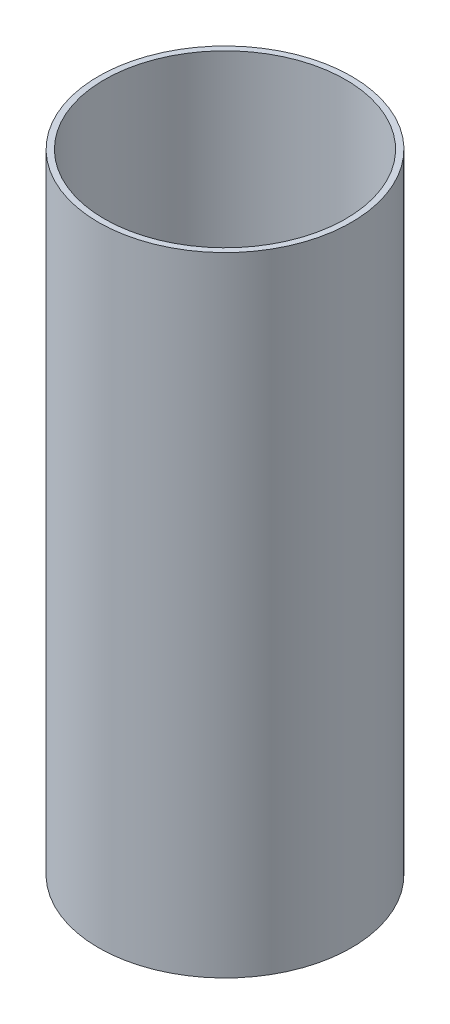
from build123d import *

# Parameters (mm, degrees)
SKETCH1_R           = 59.94
SKETCH1_R_2         = 57.15
BOSS_EXTRUDE1_DEPTH = 297.6


with BuildPart() as part:
    # Sketch1 → Boss-Extrude1 (new body)
    with BuildSketch(Plane(origin=(0, 0, 0), x_dir=(1, 0, 0), z_dir=(0, 1, 0))):
        Circle(SKETCH1_R)
        Circle(SKETCH1_R_2, mode=Mode.SUBTRACT)
    extrude(amount=BOSS_EXTRUDE1_DEPTH)


solid = part.part
